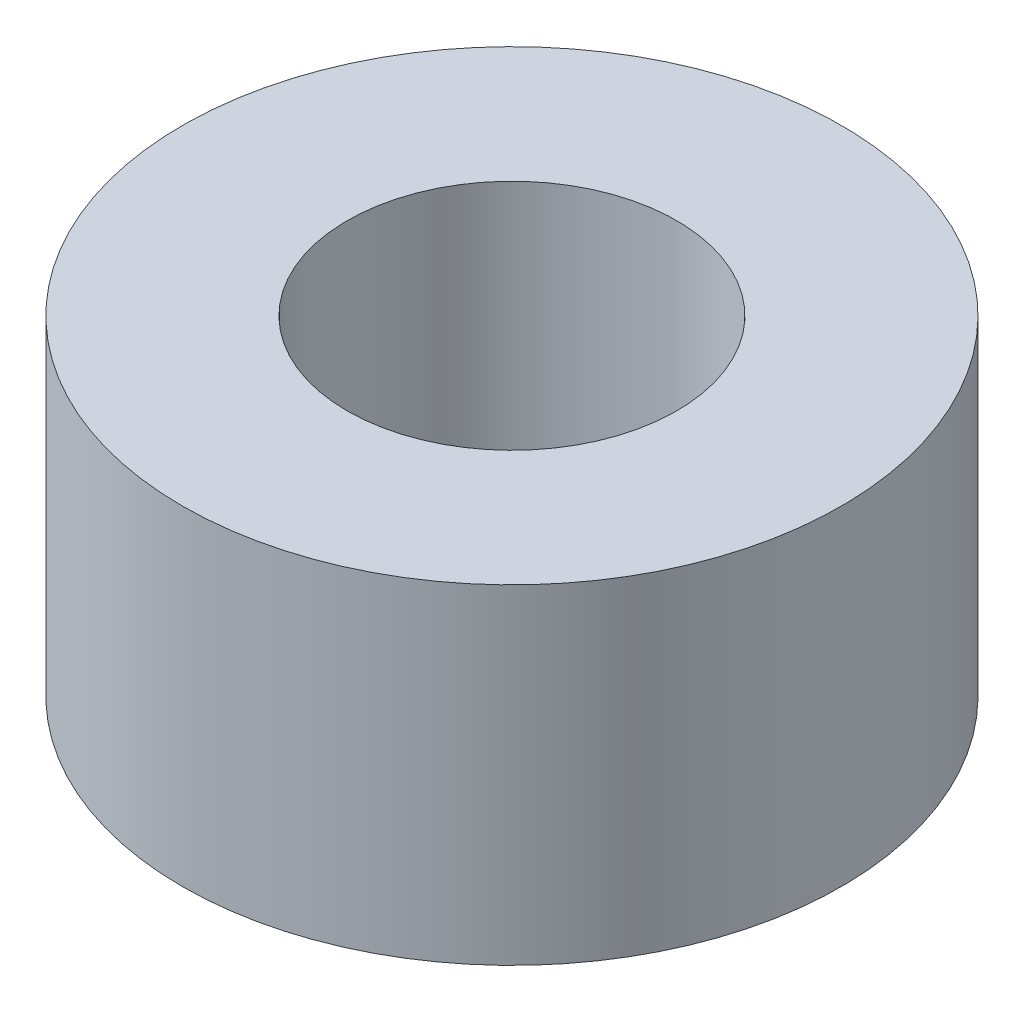
from build123d import *

# Parameters (mm, degrees)
SKETCH1_R           = 3.175
SKETCH1_R_2         = 1.5875
BOSS_EXTRUDE1_DEPTH = 3.175


with BuildPart() as part:
    # Sketch1 → Boss-Extrude1 (new body)
    with BuildSketch(Plane(origin=(0, 0, 0), x_dir=(1, 0, 0), z_dir=(0, 1, 0))):
        Circle(SKETCH1_R)
        Circle(SKETCH1_R_2, mode=Mode.SUBTRACT)
    extrude(amount=BOSS_EXTRUDE1_DEPTH)


solid = part.part
